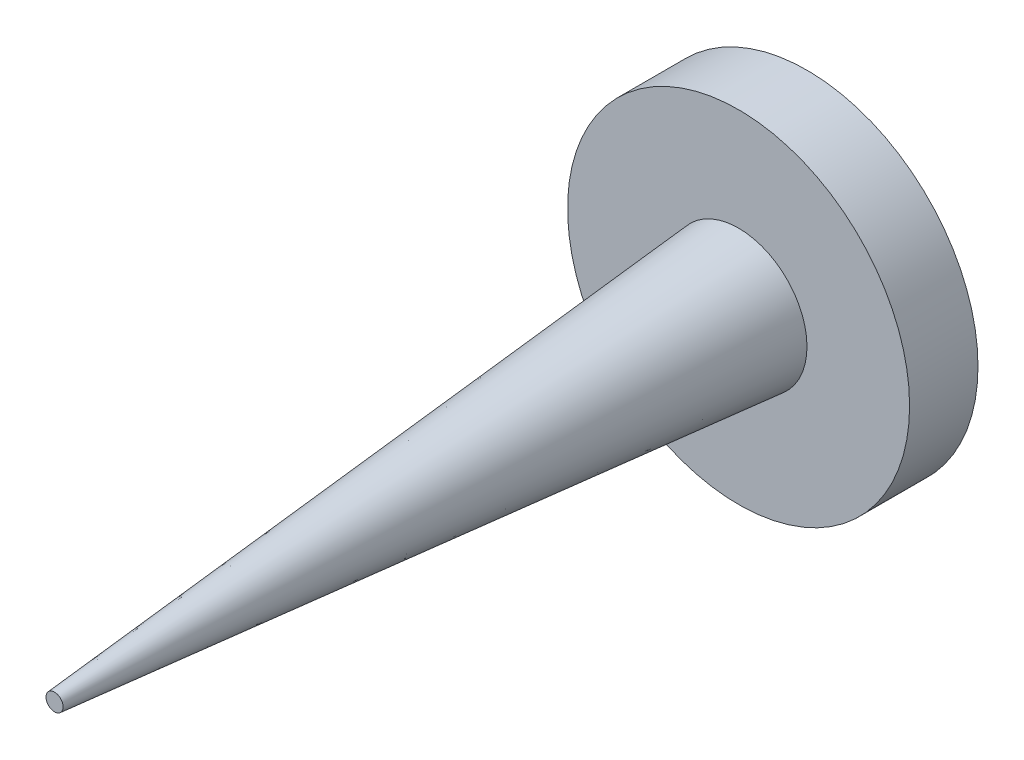
from build123d import *

# Parameters (mm, degrees)
SKETCH1_R           = 2.5
BOSS_EXTRUDE1_DEPTH = 1
SKETCH2_R           = 1
BOSS_EXTRUDE2_DEPTH = 10
BOSS_EXTRUDE2_TAPER = 5


with BuildPart() as part:
    # Sketch1 → Boss-Extrude1 (new body)
    with BuildSketch(Plane.XY):
        Circle(SKETCH1_R)
    extrude(amount=BOSS_EXTRUDE1_DEPTH)

    # Sketch2 → Boss-Extrude2 (add)
    with BuildSketch(Plane.XY.offset(1)):
        Circle(SKETCH2_R)
    extrude(amount=BOSS_EXTRUDE2_DEPTH, taper=BOSS_EXTRUDE2_TAPER)


solid = part.part
